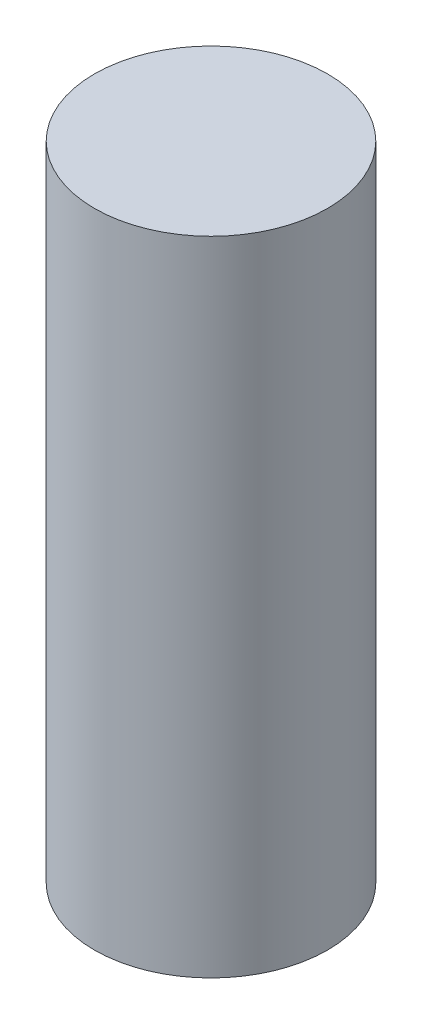
from build123d import *

# Parameters (mm, degrees)
BODY_R              = 6.35
BOSS_EXTRUDE1_DEPTH = 35
HOLE_R              = 3
CUT_EXTRUDE1_DEPTH  = 10


with BuildPart() as part:
    # body → Boss-Extrude1 (new body)
    with BuildSketch(Plane(origin=(0, 0, 0), x_dir=(1, 0, 0), z_dir=(0, 1, 0))):
        Circle(BODY_R)
    extrude(amount=BOSS_EXTRUDE1_DEPTH)

    # hole → Cut-Extrude1 (cut)
    with BuildSketch(Plane(origin=(0, 0, 0), x_dir=(1, 0, 0), z_dir=(0, 1, 0))):
        Circle(HOLE_R)
    extrude(amount=CUT_EXTRUDE1_DEPTH, mode=Mode.SUBTRACT)


solid = part.part
